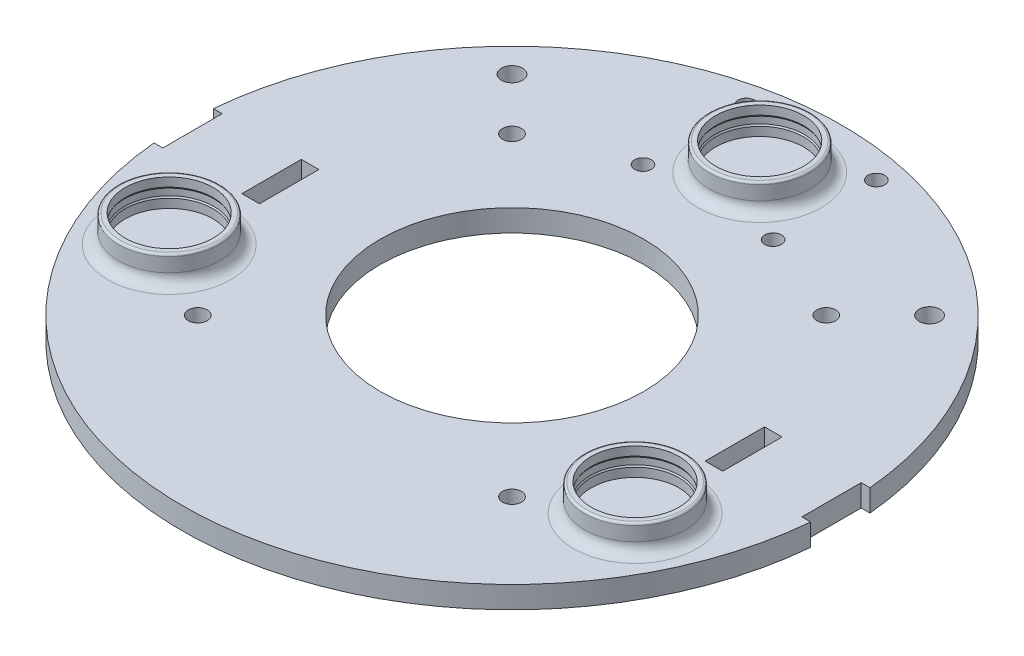
from build123d import *

# Parameters (mm, degrees)
SKETCH1_R                             = 75
BASE_DEPTH                            = 5
MAIN_WHEEL_SLOTS_REACH                = 7
SKETCH2_W                             = 4
SKETCH2_H                             = 13.5
F_3RD_WHEEL_HOLES_REACH               = 7
SKETCH3_R                             = 1.9
SKETCH6_R                             = 2.15
FAN_SCREW_HOLES_DEPTH                 = 6
FAN_BLADE_HOLE_REACH                  = 7
SKETCH7_R                             = 30
TOP_PEG_BOTTOM_FILLET_R               = 2.5
TOP_PEG_TOP_FILLET_R                  = 0.5
RIGHT_PEG_BOTTOM_FILLET_R             = 2.5
RIGHT_PEG_TOP_FILLET_R                = 0.5
RIGHT_PEG_BOTTOM_FILLET_OF_LEFT_PEG_R = 2.5
RIGHT_PEG_TOP_FILLET_OF_LEFT_PEG_R    = 0.5
SWITCH_HOLES_REACH                    = 7
SKETCH12_R                            = 2.4


with BuildPart() as part:
    # Sketch1 → Base (new body)
    with BuildSketch(Plane(origin=(0, 0, 0), x_dir=(1, 0, 0), z_dir=(0, 1, 0))):
        Circle(SKETCH1_R)
    extrude(amount=BASE_DEPTH)

    # Sketch2 → Main Wheel Slots (cut, up to next)
    with BuildSketch(Plane(origin=(0, 5, 0), x_dir=(1, 0, 0), z_dir=(0, 1, 0)), mode=Mode.PRIVATE) as main_wheel_slots_sk1:
        with Locations((52.695632402, 0)):
            Rectangle(SKETCH2_W, SKETCH2_H)
    main_wheel_slots_tool1 = extrude(main_wheel_slots_sk1.sketch, amount=-MAIN_WHEEL_SLOTS_REACH, mode=Mode.PRIVATE) & part.part
    add(main_wheel_slots_tool1.solids().sort_by_distance((52.695632, 5, 0))[0], mode=Mode.SUBTRACT)
    # Sketch2 → Main Wheel Slots (cut, up to next)
    with BuildSketch(Plane(origin=(0, 5, 0), x_dir=(1, 0, 0), z_dir=(0, 1, 0)), mode=Mode.PRIVATE) as main_wheel_slots_sk2:
        with BuildLine():
            ThreePointArc((75, 0), (74.923869462, 3.378429355), (74.695632402, 6.75))
            Line((74.695632402, 6.75), (72.695632402, 6.75))
            Line((72.695632402, 6.75), (72.695632402, -6.75))
            Line((72.695632402, -6.75), (74.695632402, -6.75))
            ThreePointArc((74.695632402, -6.75), (74.923869462, -3.378429355), (75, 0))
        make_face()
    main_wheel_slots_tool2 = extrude(main_wheel_slots_sk2.sketch, amount=-MAIN_WHEEL_SLOTS_REACH, mode=Mode.PRIVATE) & part.part
    add(main_wheel_slots_tool2.solids().sort_by_distance((73.798997, 5, 0))[0], mode=Mode.SUBTRACT)
    # Sketch2 → Main Wheel Slots (cut, up to next)
    with BuildSketch(Plane(origin=(0, 5, 0), x_dir=(1, 0, 0), z_dir=(0, 1, 0)), mode=Mode.PRIVATE) as main_wheel_slots_sk3:
        with BuildLine():
            Line((-72.695632402, 6.75), (-74.695632402, 6.75))
            ThreePointArc((-74.695632402, 6.75), (-75, 0), (-74.695632402, -6.75))
            Line((-74.695632402, -6.75), (-72.695632402, -6.75))
            Line((-72.695632402, -6.75), (-72.695632402, 6.75))
        make_face()
    main_wheel_slots_tool3 = extrude(main_wheel_slots_sk3.sketch, amount=-MAIN_WHEEL_SLOTS_REACH, mode=Mode.PRIVATE) & part.part
    add(main_wheel_slots_tool3.solids().sort_by_distance((-73.798997, 5, 0))[0], mode=Mode.SUBTRACT)
    # Sketch2 → Main Wheel Slots (cut, up to next)
    with BuildSketch(Plane(origin=(0, 5, 0), x_dir=(1, 0, 0), z_dir=(0, 1, 0)), mode=Mode.PRIVATE) as main_wheel_slots_sk4:
        with Locations((-52.695632402, 0)):
            Rectangle(SKETCH2_W, SKETCH2_H)
    main_wheel_slots_tool4 = extrude(main_wheel_slots_sk4.sketch, amount=-MAIN_WHEEL_SLOTS_REACH, mode=Mode.PRIVATE) & part.part
    add(main_wheel_slots_tool4.solids().sort_by_distance((-52.695632, 5, 0))[0], mode=Mode.SUBTRACT)

    # Sketch3 → 3rd Wheel Holes (cut, up to next)
    with BuildSketch(Plane(origin=(0, 5, 0), x_dir=(1, 0, 0), z_dir=(0, 1, 0)), mode=Mode.PRIVATE) as f_3rd_wheel_holes_sk1:
        with Locations((14.8, 68.1)):
            Circle(SKETCH3_R)
    f_3rd_wheel_holes_tool1 = extrude(f_3rd_wheel_holes_sk1.sketch, amount=-F_3RD_WHEEL_HOLES_REACH, mode=Mode.PRIVATE) & part.part
    add(f_3rd_wheel_holes_tool1.solids().sort_by_distance((14.8, 5, -68.1))[0], mode=Mode.SUBTRACT)
    # Sketch3 → 3rd Wheel Holes (cut, up to next)
    with BuildSketch(Plane(origin=(0, 5, 0), x_dir=(1, 0, 0), z_dir=(0, 1, 0)), mode=Mode.PRIVATE) as f_3rd_wheel_holes_sk2:
        with Locations((14.8, 44.6)):
            Circle(SKETCH3_R)
    f_3rd_wheel_holes_tool2 = extrude(f_3rd_wheel_holes_sk2.sketch, amount=-F_3RD_WHEEL_HOLES_REACH, mode=Mode.PRIVATE) & part.part
    add(f_3rd_wheel_holes_tool2.solids().sort_by_distance((14.8, 5, -44.6))[0], mode=Mode.SUBTRACT)
    # Sketch3 → 3rd Wheel Holes (cut, up to next)
    with BuildSketch(Plane(origin=(0, 5, 0), x_dir=(1, 0, 0), z_dir=(0, 1, 0)), mode=Mode.PRIVATE) as f_3rd_wheel_holes_sk3:
        with Locations((-14.8, 44.6)):
            Circle(SKETCH3_R)
    f_3rd_wheel_holes_tool3 = extrude(f_3rd_wheel_holes_sk3.sketch, amount=-F_3RD_WHEEL_HOLES_REACH, mode=Mode.PRIVATE) & part.part
    add(f_3rd_wheel_holes_tool3.solids().sort_by_distance((-14.8, 5, -44.6))[0], mode=Mode.SUBTRACT)
    # Sketch3 → 3rd Wheel Holes (cut, up to next)
    with BuildSketch(Plane(origin=(0, 5, 0), x_dir=(1, 0, 0), z_dir=(0, 1, 0)), mode=Mode.PRIVATE) as f_3rd_wheel_holes_sk4:
        with Locations((-14.8, 68.1)):
            Circle(SKETCH3_R)
    f_3rd_wheel_holes_tool4 = extrude(f_3rd_wheel_holes_sk4.sketch, amount=-F_3RD_WHEEL_HOLES_REACH, mode=Mode.PRIVATE) & part.part
    add(f_3rd_wheel_holes_tool4.solids().sort_by_distance((-14.8, 5, -68.1))[0], mode=Mode.SUBTRACT)

    # Sketch6 → Fan Screw Holes (cut)
    with BuildSketch(Plane(origin=(0, 5, 0), x_dir=(1, 0, 0), z_dir=(0, 1, 0))):
        with Locations((35.75, 35.75)):
            Circle(SKETCH6_R)
        with Locations((-35.75, 35.75)):
            Circle(SKETCH6_R)
        with Locations((-35.75, -35.75)):
            Circle(SKETCH6_R)
        with Locations((35.75, -35.75)):
            Circle(SKETCH6_R)
    extrude(amount=-FAN_SCREW_HOLES_DEPTH, mode=Mode.SUBTRACT)

    # Sketch7 → Fan Blade Hole (cut, up to next)
    with BuildSketch(Plane(origin=(0, 5, 0), x_dir=(1, 0, 0), z_dir=(0, 1, 0)), mode=Mode.PRIVATE) as fan_blade_hole_sk1:
        Circle(SKETCH7_R)
    fan_blade_hole_tool1 = extrude(fan_blade_hole_sk1.sketch, amount=-FAN_BLADE_HOLE_REACH, mode=Mode.PRIVATE) & part.part
    add(fan_blade_hole_tool1.solids().sort_by_distance((0, 5, 0))[0], mode=Mode.SUBTRACT)

    # Sketch10 → Top Peg Base (revolve)
    with BuildSketch(Plane.XY.offset(-56.35)):
        Polygon((10, 5), (10, 7), (10.2, 7.346410162), (10.2, 8.846410162), (10, 9.192820323), (10, 11.192820323), (11.5, 11.192820323), (11.5, 5), align=None)
    revolve(axis=Axis((0, 5, -56.35), (0, 1, 0)))

    # Top Peg Bottom Fillet
    top_peg_bottom_fillet_edges = [part.edges().sort_by_distance(p)[0] for p in [
        (-11.5, 5, -56.35),
    ]]
    fillet(top_peg_bottom_fillet_edges, radius=TOP_PEG_BOTTOM_FILLET_R)

    # Top Peg Top Fillet
    top_peg_top_fillet_edges = [part.edges().sort_by_distance(p)[0] for p in [
        (-11.5, 11.192820323, -56.35),
    ]]
    fillet(top_peg_top_fillet_edges, radius=TOP_PEG_TOP_FILLET_R)

    # Sketch11 → Right Peg Base (revolve)
    with BuildSketch(Plane.XY.offset(25)):
        Polygon((63, 5), (63, 7), (63.2, 7.346410162), (63.2, 8.846410162), (63, 9.192820323), (63, 11.192820323), (64.5, 11.192820323), (64.5, 5), align=None)
    right_peg_base = revolve(axis=Axis((53, 5, 25), (0, 1, 0)))

    # Right Peg Bottom Fillet
    right_peg_bottom_fillet_edges = [part.edges().sort_by_distance(p)[0] for p in [
        (41.5, 5, 25),
    ]]
    fillet(right_peg_bottom_fillet_edges, radius=RIGHT_PEG_BOTTOM_FILLET_R)

    # Right Peg Top Fillet
    right_peg_top_fillet_edges = [part.edges().sort_by_distance(p)[0] for p in [
        (41.5, 11.192820323, 25),
    ]]
    fillet(right_peg_top_fillet_edges, radius=RIGHT_PEG_TOP_FILLET_R)

    # Left Peg: Right Peg Base across plane
    add(right_peg_base.mirror(Plane(origin=(0, 0, 0), x_dir=(0, 0, 1), z_dir=(1, 0, 0))))

    # Right Peg Bottom Fillet of Left Peg
    right_peg_bottom_fillet_of_left_peg_edges = [part.edges().sort_by_distance(p)[0] for p in [
        (-41.5, 5, 25),
    ]]
    fillet(right_peg_bottom_fillet_of_left_peg_edges, radius=RIGHT_PEG_BOTTOM_FILLET_OF_LEFT_PEG_R)

    # Right Peg Top Fillet of Left Peg
    right_peg_top_fillet_of_left_peg_edges = [part.edges().sort_by_distance(p)[0] for p in [
        (-41.5, 11.192820323, 25),
    ]]
    fillet(right_peg_top_fillet_of_left_peg_edges, radius=RIGHT_PEG_TOP_FILLET_OF_LEFT_PEG_R)

    # Sketch12 → Switch Holes (cut, up to next)
    with BuildSketch(Plane(origin=(0, 5, 0), x_dir=(1, 0, 0), z_dir=(0, 1, 0)), mode=Mode.PRIVATE) as switch_holes_sk1:
        with Locations((47.5, 47.5)):
            Circle(SKETCH12_R)
    switch_holes_tool1 = extrude(switch_holes_sk1.sketch, amount=-SWITCH_HOLES_REACH, mode=Mode.PRIVATE) & part.part
    add(switch_holes_tool1.solids().sort_by_distance((47.5, 5, -47.5))[0], mode=Mode.SUBTRACT)
    # Sketch12 → Switch Holes (cut, up to next)
    with BuildSketch(Plane(origin=(0, 5, 0), x_dir=(1, 0, 0), z_dir=(0, 1, 0)), mode=Mode.PRIVATE) as switch_holes_sk2:
        with Locations((-47.5, 47.5)):
            Circle(SKETCH12_R)
    switch_holes_tool2 = extrude(switch_holes_sk2.sketch, amount=-SWITCH_HOLES_REACH, mode=Mode.PRIVATE) & part.part
    add(switch_holes_tool2.solids().sort_by_distance((-47.5, 5, -47.5))[0], mode=Mode.SUBTRACT)


solid = part.part
